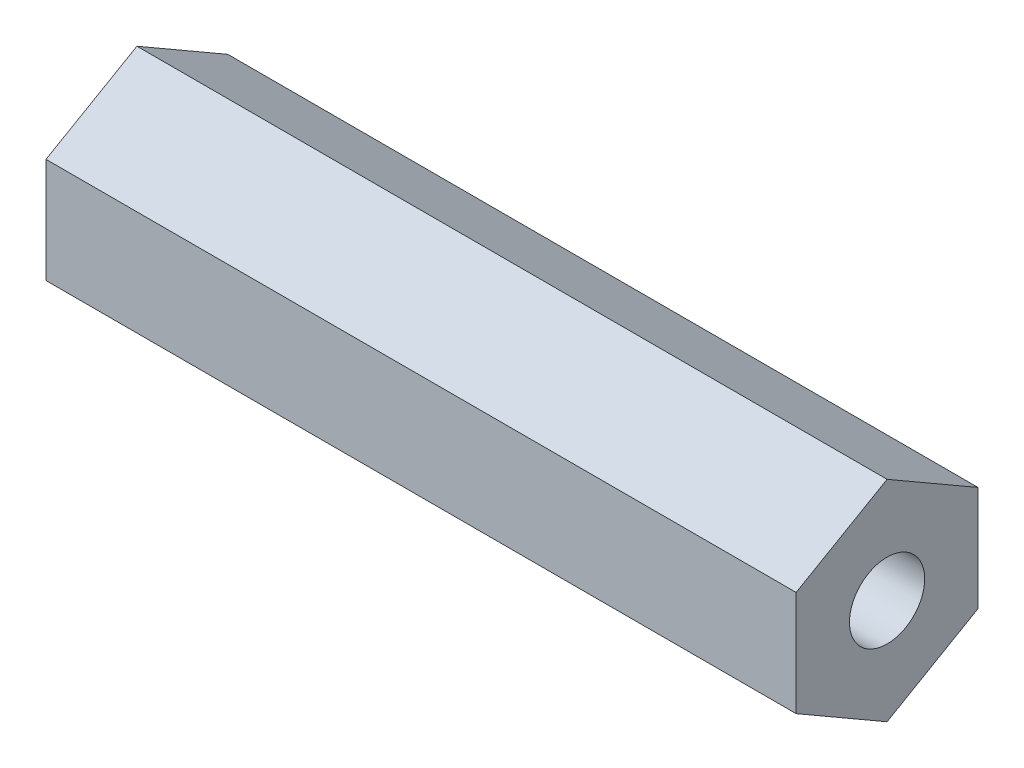
from build123d import *

# Parameters (mm, degrees)
SKETCH2_R           = 2.6289
BOSS_EXTRUDE1_DEPTH = 52.3875


with BuildPart() as part:
    # Sketch2 → Boss-Extrude1 (new body)
    with BuildSketch(Plane(origin=(0, 0, 0), x_dir=(0, 0, -1), z_dir=(1, 0, 0))):
        Polygon((0, 7.332348419), (-6.35, 3.666174209), (-6.35, -3.666174209), (0, -7.332348419), (6.35, -3.666174209), (6.35, 3.666174209), align=None)
        Circle(SKETCH2_R, mode=Mode.SUBTRACT)
    extrude(amount=BOSS_EXTRUDE1_DEPTH)


solid = part.part
